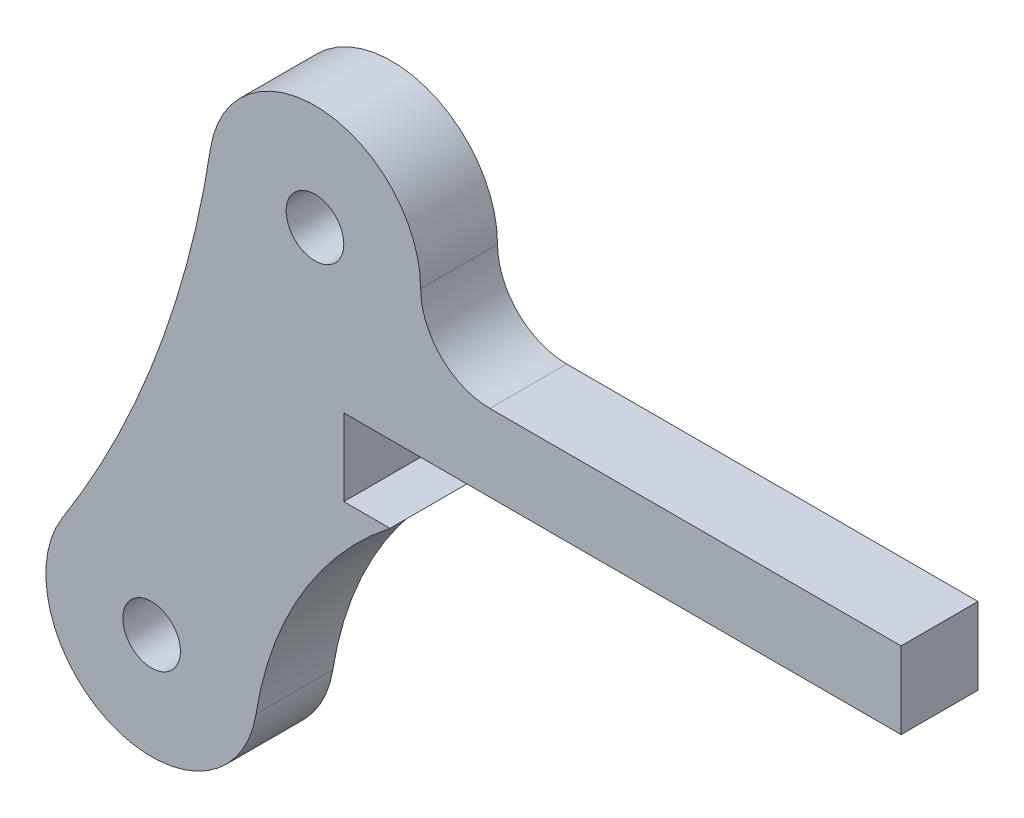
from build123d import *

# Parameters (mm, degrees)
SKETCH1_R           = 1.5
BOSS_EXTRUDE1_DEPTH = 4
SKETCH2_W           = 29
SKETCH2_H           = 4
CUT_EXTRUDE1_DEPTH  = 10


with BuildPart() as part:
    # Sketch1 → Boss-Extrude1 (new body)
    with BuildSketch(Plane.XY):
        with BuildLine():
            Line((30.5, -3.6), (9.1, -3.6))
            ThreePointArc((9.1, -3.6), (6.554415588, -2.545584412), (5.5, 0))
            ThreePointArc((5.5, 0), (0.421431882, 5.483830337), (-5.435416425, 0.840385797))
            ThreePointArc((-5.435416425, 0.840385797), (-8.227950432, -9.8038682), (-13.142048472, -19.650188822))
            ThreePointArc((-13.142048472, -19.650188822), (-10.445387128, -27.744460023), (-3.067628607, -23.459849435))
            ThreePointArc((-3.067628607, -23.459849435), (3.290458074, -12.104682623), (15.5, -7.6))
            Line((15.5, -7.6), (30.5, -7.6))
            Line((30.5, -7.6), (30.5, -3.6))
        make_face()
        Circle(SKETCH1_R, mode=Mode.SUBTRACT)
        with Locations((-8.5, -22.6)):
            Circle(SKETCH1_R, mode=Mode.SUBTRACT)
    extrude(amount=BOSS_EXTRUDE1_DEPTH)

    # Sketch2 → Cut-Extrude1 (cut)
    with BuildSketch(Plane.XY.offset(4)):
        with Locations((16, -9.6)):
            Rectangle(SKETCH2_W, SKETCH2_H)
    extrude(amount=-CUT_EXTRUDE1_DEPTH, mode=Mode.SUBTRACT)


solid = part.part
